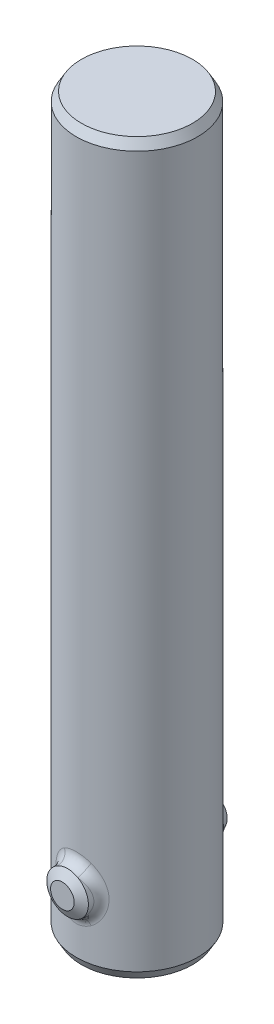
from build123d import *

# Parameters (mm, degrees)
BOSS_EXTRUDE1_START   = 4.175578
SKETCH2_R             = 1.524
BOSS_EXTRUDE1_DEPTH   = 1.285422
CHAMFER1_SIZE         = 0.381
CHAMFER1_SIZE2        = 0.659911358
CHAMFER1_PART_2_SIZE  = 0.381
CHAMFER1_PART_2_SIZE2 = 0.659911358
CHAMFER1_PART_3_SIZE  = 0.381
CHAMFER1_PART_3_SIZE2 = 0.659911358
CHAMFER1_PART_4_SIZE  = 0.381
CHAMFER1_PART_4_SIZE2 = 0.659911358
FILLET1_R             = 0.762


with BuildPart() as part:
    # Sketch1 → Revolve1 (revolve)
    with BuildSketch(Plane.XY, mode=Mode.PRIVATE) as revolve1_sk:
        Polygon((3.302, 0), (3.302, 50.8), (0, 50.8), (0, 53.34), (4.445, 53.34), (4.445, 0), align=None)
    revolve(revolve1_sk.sketch.rotate(Axis((0, 50.8, 0), (0, -1, 0)), 90), axis=Axis((0, 50.8, 0), (0, -1, 0)))  # turned: the seam where the file's is

    # Sketch2 → Boss-Extrude1 (add)
    with BuildSketch(Plane.XY.offset(BOSS_EXTRUDE1_START)):
        with Locations((0, 5.08)):
            Circle(SKETCH2_R)
    boss_extrude1 = extrude(amount=BOSS_EXTRUDE1_DEPTH)

    # Mirror1: Boss-Extrude1 across plane
    add(boss_extrude1.mirror(Plane.XY))

    # Chamfer1
    chamfer1_edges = [part.edges().sort_by_distance(p)[0] for p in [
        (-1.524, 5.08, 5.461),
    ]]
    chamfer1_side = [part.faces().sort_by_distance(p)[0] for p in [
        (-1.524, 5.08, 4.818258203),
    ]]
    chamfer(chamfer1_edges, length=CHAMFER1_SIZE, length2=CHAMFER1_SIZE2, reference=chamfer1_side[0])

    # Chamfer1 part 2
    chamfer1_part_2_edges = [part.edges().sort_by_distance(p)[0] for p in [
        (-1.524, 5.08, -5.461),
    ]]
    chamfer1_part_2_side = [part.faces().sort_by_distance(p)[0] for p in [
        (0, 5.08, -5.461),
    ]]
    chamfer(chamfer1_part_2_edges, length=CHAMFER1_PART_2_SIZE, length2=CHAMFER1_PART_2_SIZE2, reference=chamfer1_part_2_side[0])

    # Chamfer1 part 3
    chamfer1_part_3_edges = [part.edges().sort_by_distance(p)[0] for p in [
        (0, 0, -4.445),
        (0, 0, -3.302),
    ]]
    chamfer1_part_3_side = [part.faces().sort_by_distance(p)[0] for p in [
        (0, 0, -4.319276414),
    ]]
    chamfer(chamfer1_part_3_edges, length=CHAMFER1_PART_3_SIZE, length2=CHAMFER1_PART_3_SIZE2, reference=chamfer1_part_3_side[0])

    # Chamfer1 part 4
    chamfer1_part_4_edges = [part.edges().sort_by_distance(p)[0] for p in [
        (0, 53.34, -4.445),
    ]]
    chamfer1_part_4_side = [part.faces().sort_by_distance(p)[0] for p in [
        (0, 53.34, 0),
    ]]
    chamfer(chamfer1_part_4_edges, length=CHAMFER1_PART_4_SIZE, length2=CHAMFER1_PART_4_SIZE2, reference=chamfer1_part_4_side[0])

    # Fillet1
    fillet1_edges = [part.edges().sort_by_distance(p)[0] for p in [
        (-1.524, 5.08, 4.175577685),
        (-1.524, 5.08, -4.175577685),
    ]]
    fillet(fillet1_edges, radius=FILLET1_R)


solid = part.part
